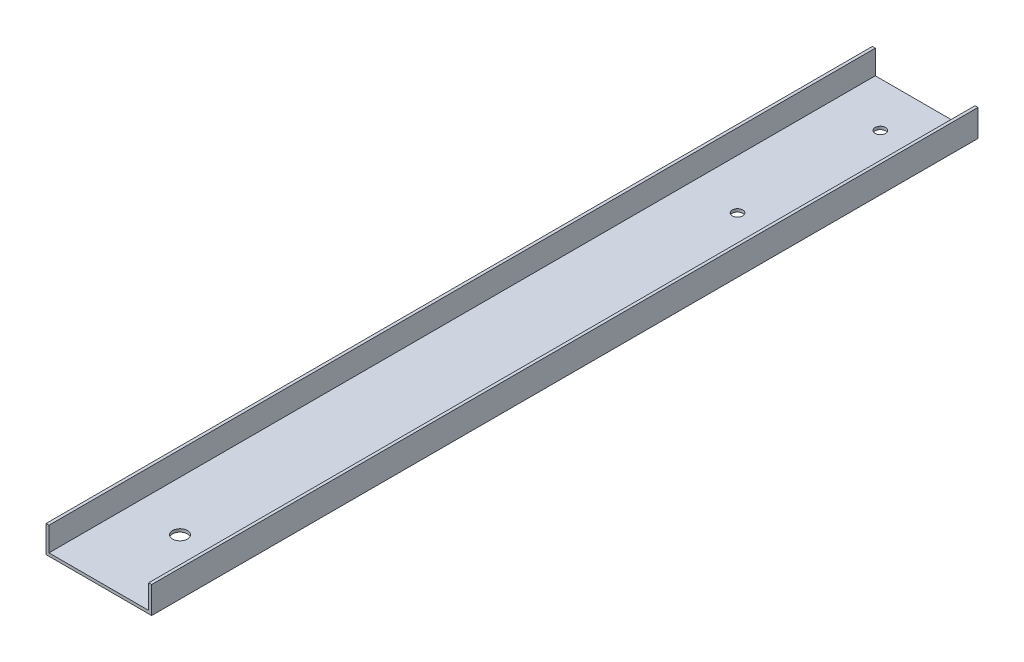
from build123d import *

# Parameters (mm, degrees)
BOSS_EXTRUDE1_DEPTH = 354.0125
SKETCH2_R           = 2.2225
SKETCH2_R_2         = 3.175
CUT_EXTRUDE1_DEPTH  = 1.27


with BuildPart() as part:
    # Sketch1 → Boss-Extrude1 (new body)
    with BuildSketch(Plane.XY):
        Polygon((0, 0), (0, -11.5316), (45.2628, -11.5316), (45.2628, 0), (43.9928, 0), (43.9928, -10.2616), (1.27, -10.2616), (1.27, 0), align=None)
    extrude(amount=BOSS_EXTRUDE1_DEPTH)

    # Sketch2 → Cut-Extrude1 (cut)
    with BuildSketch(Plane(origin=(0, -11.5316, 0), x_dir=(-1, 0, 0), z_dir=(0, -1, 0))):
        with Locations((-22.6314, -19.1897)):
            Circle(SKETCH2_R)
        with Locations((-22.6314, -80.391)):
            Circle(SKETCH2_R)
        with Locations((-22.6314, -319.2145)):
            Circle(SKETCH2_R_2)
    extrude(amount=-CUT_EXTRUDE1_DEPTH, mode=Mode.SUBTRACT)


solid = part.part
